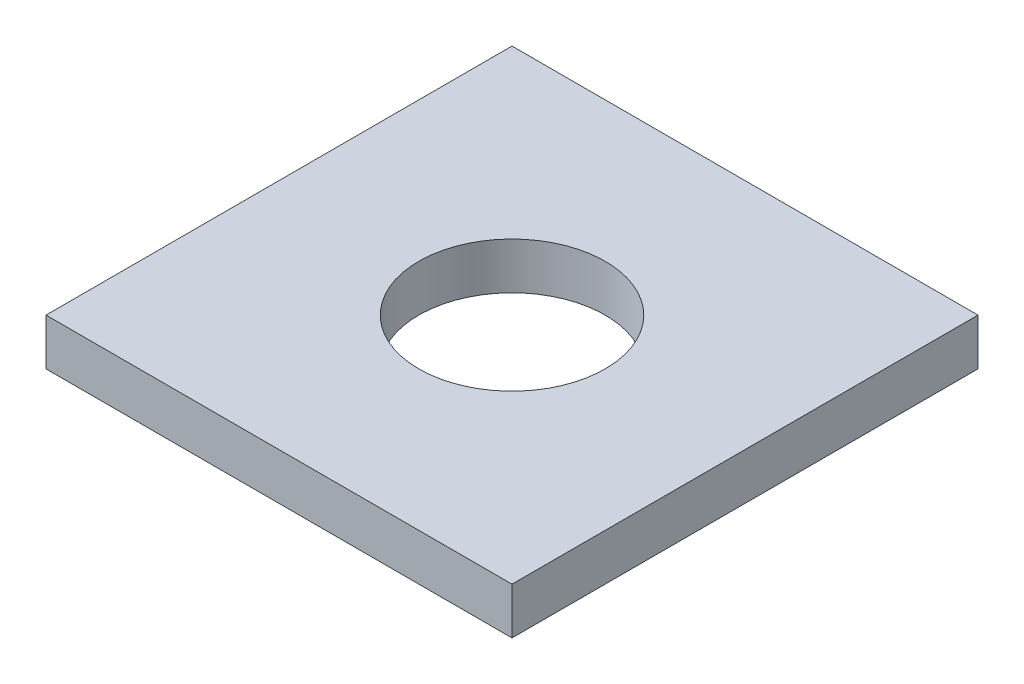
from build123d import *

# Parameters (mm, degrees)
SKETCH1_W           = 31.75
SKETCH1_H           = 31.75
SKETCH1_R           = 6.35
BOSS_EXTRUDE1_DEPTH = 1.5875


with BuildPart() as part:
    # Sketch1 → Boss-Extrude1 (new body, symmetric)
    with BuildSketch(Plane(origin=(0, 0, 0), x_dir=(1, 0, 0), z_dir=(0, 1, 0))):
        Rectangle(SKETCH1_W, SKETCH1_H)
        Circle(SKETCH1_R, mode=Mode.SUBTRACT)
    extrude(amount=BOSS_EXTRUDE1_DEPTH, both=True)


solid = part.part
